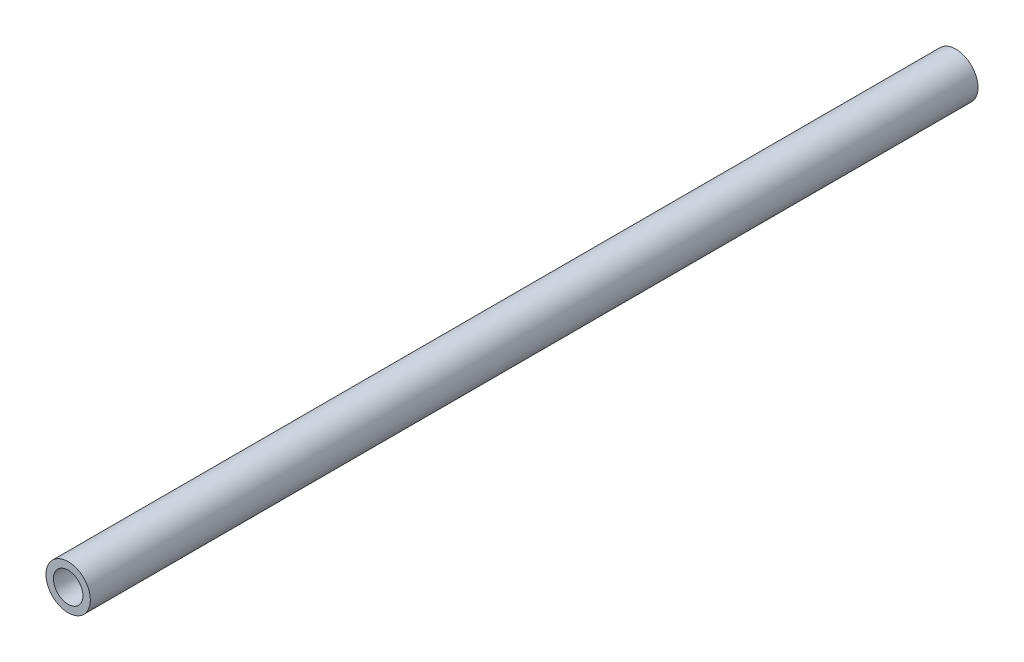
from build123d import *

# Parameters (mm, degrees)
SKETCH1_R           = 7.62
SKETCH1_R_2         = 5.08
BOSS_EXTRUDE1_DEPTH = 304.8


with BuildPart() as part:
    # Sketch1 → Boss-Extrude1 (new body)
    with BuildSketch(Plane.XY):
        Circle(SKETCH1_R)
        Circle(SKETCH1_R_2, mode=Mode.SUBTRACT)
    extrude(amount=BOSS_EXTRUDE1_DEPTH)


solid = part.part
